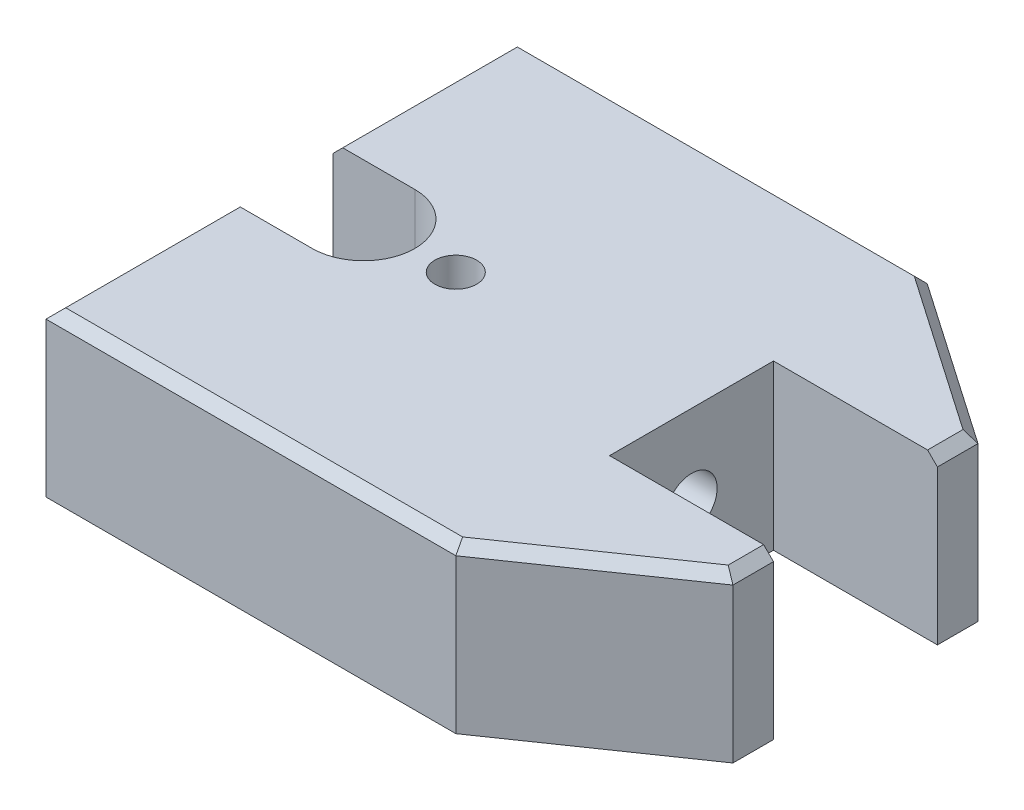
from build123d import *

# Parameters (mm, degrees)
BOSS_EXTRUDE2_DEPTH         = 12.7
SKETCH3_W                   = 25.4
SKETCH3_H                   = 25.4
CUT_EXTRUDE1_DEPTH          = 26.4
CUT_EXTRUDE3_DEPTH          = 26.4
HOLE1_D                     = 6.477
HOLE1_DEPTH                 = 14.2748
F_3_8_16_TAPPED_HOLE1_D     = 7.9375
F_3_8_16_TAPPED_HOLE1_DEPTH = 20.32
F_3_8_16_TAPPED_HOLE1_TIP   = 2.384665582
CHAMFER1_SIZE               = 1.524


with BuildPart() as part:
    # Sketch2 → Boss-Extrude2 (new body, symmetric)
    with BuildSketch(Plane(origin=(0, 0, 0), x_dir=(1, 0, 0), z_dir=(0, 1, 0))):
        Polygon((0, 36.5125), (0, -36.5125), (63.5, -36.5125), (88.9, -18.9865), (88.9, 18.9865), (63.5, 36.5125), align=None)
    extrude(amount=BOSS_EXTRUDE2_DEPTH, both=True)

    # Sketch3 → Cut-Extrude1 (cut, through all)
    with BuildSketch(Plane(origin=(0, 12.7, 0), x_dir=(1, 0, 0), z_dir=(0, 1, 0))):
        with Locations((76.2, 0)):
            Rectangle(SKETCH3_W, SKETCH3_H)
    extrude(amount=-CUT_EXTRUDE1_DEPTH, mode=Mode.SUBTRACT)

    # Sketch4 → Cut-Extrude3 (cut, through all)
    with BuildSketch(Plane(origin=(0, 12.7, 0), x_dir=(1, 0, 0), z_dir=(0, 1, 0))):
        with BuildLine():
            Line((0, 7.9375), (12.6873, 7.9375))
            ThreePointArc((12.6873, 7.9375), (20.6248, 0), (12.6873, -7.9375))
            Line((12.6873, -7.9375), (0, -7.9375))
            Line((0, -7.9375), (0, 7.9375))
        make_face()
    extrude(amount=-CUT_EXTRUDE3_DEPTH, mode=Mode.SUBTRACT)

    # Hole1
    with Locations(Plane(origin=(0, 12.7, 0), x_dir=(1, 0, 0), z_dir=(0, 1, 0))):
        with Locations((26.9748, 0)):
            Hole(HOLE1_D / 2, depth=HOLE1_DEPTH)

    # 3/8-16 Tapped Hole1
    with Locations(Plane(origin=(63.5, 0, 0), x_dir=(0, 0, -1), z_dir=(1, 0, 0))):
        with Locations((0, 0)):
            Hole(F_3_8_16_TAPPED_HOLE1_D / 2, depth=F_3_8_16_TAPPED_HOLE1_DEPTH)
            with Locations((0, 0, -(F_3_8_16_TAPPED_HOLE1_DEPTH + F_3_8_16_TAPPED_HOLE1_TIP / 2))):  # 118° drill point
                Cone(0, F_3_8_16_TAPPED_HOLE1_D / 2, F_3_8_16_TAPPED_HOLE1_TIP, mode=Mode.SUBTRACT)

    # Chamfer1
    chamfer1_edges = [part.edges().sort_by_distance(p)[0] for p in [
        (31.75, 12.7, 36.5125),
        (76.2, 12.7, 27.7495),
        (88.9, 12.7, 15.84325),
        (76.2, 12.7, -27.7495),
        (88.9, 12.7, -15.84325),
        (0, 12.7, 22.225),
        (31.75, 12.7, -36.5125),
        (0, 12.7, -22.225),
    ]]
    chamfer(chamfer1_edges, length=CHAMFER1_SIZE)


solid = part.part
